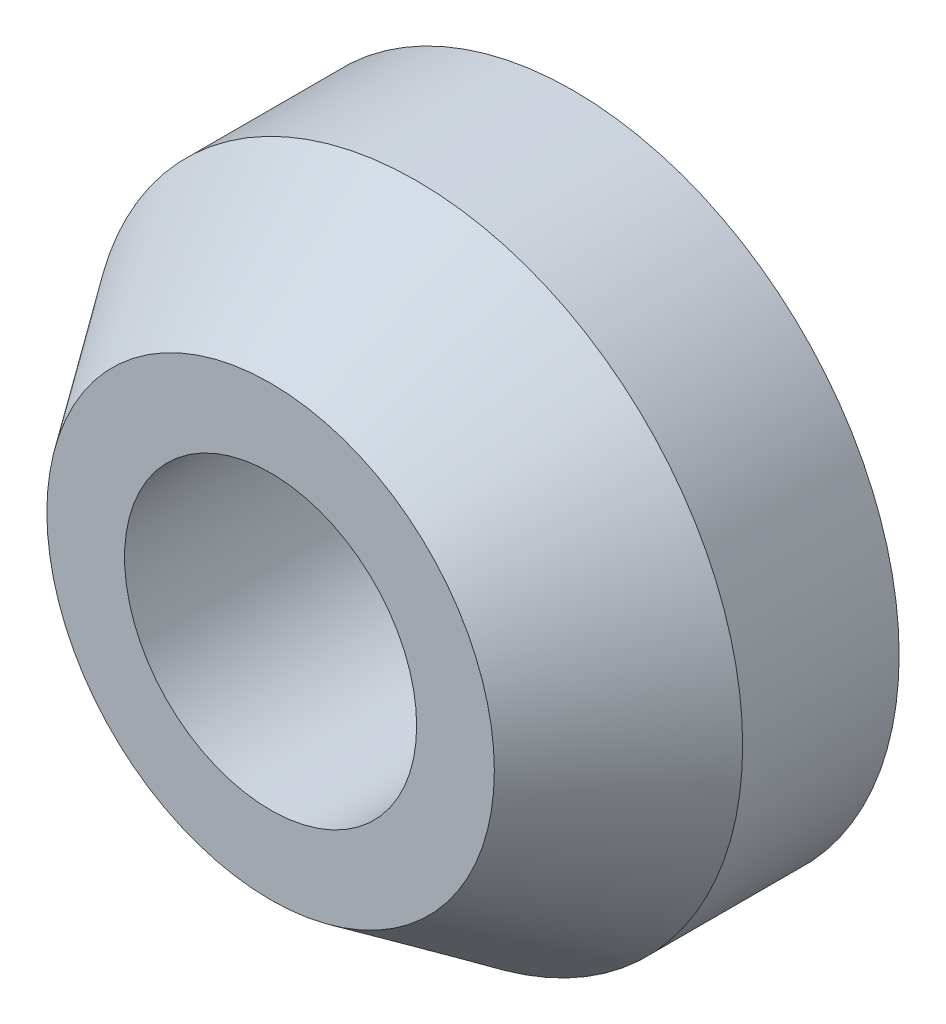
from build123d import *

# Parameters (mm, degrees)
SKETCH1_R      = 3.175
EXTRUDE1_DEPTH = 2.9464
SKETCH2_R      = 1.4224
EXTRUDE2_DEPTH = 3.9464
CHAMFER1_SIZE  = 1.4224
CHAMFER1_SIZE2 = 0.995975202


with BuildPart() as part:
    # Sketch1 → Extrude1 (new body)
    with BuildSketch(Plane.XY):
        Circle(SKETCH1_R)
    extrude(amount=EXTRUDE1_DEPTH)

    # Sketch2 → Extrude2 (cut, through all)
    with BuildSketch(Plane.XY.offset(2.9464)):
        Circle(SKETCH2_R)
    extrude(amount=-EXTRUDE2_DEPTH, mode=Mode.SUBTRACT)

    # Chamfer1
    chamfer1_edges = [part.edges().sort_by_distance(p)[0] for p in [
        (-3.175, 0, 2.9464),
    ]]
    chamfer1_side = [part.faces().sort_by_distance(p)[0] for p in [
        (-3.175, 0, 1.4732),
    ]]
    chamfer(chamfer1_edges, length=CHAMFER1_SIZE, length2=CHAMFER1_SIZE2, reference=chamfer1_side[0])


solid = part.part
